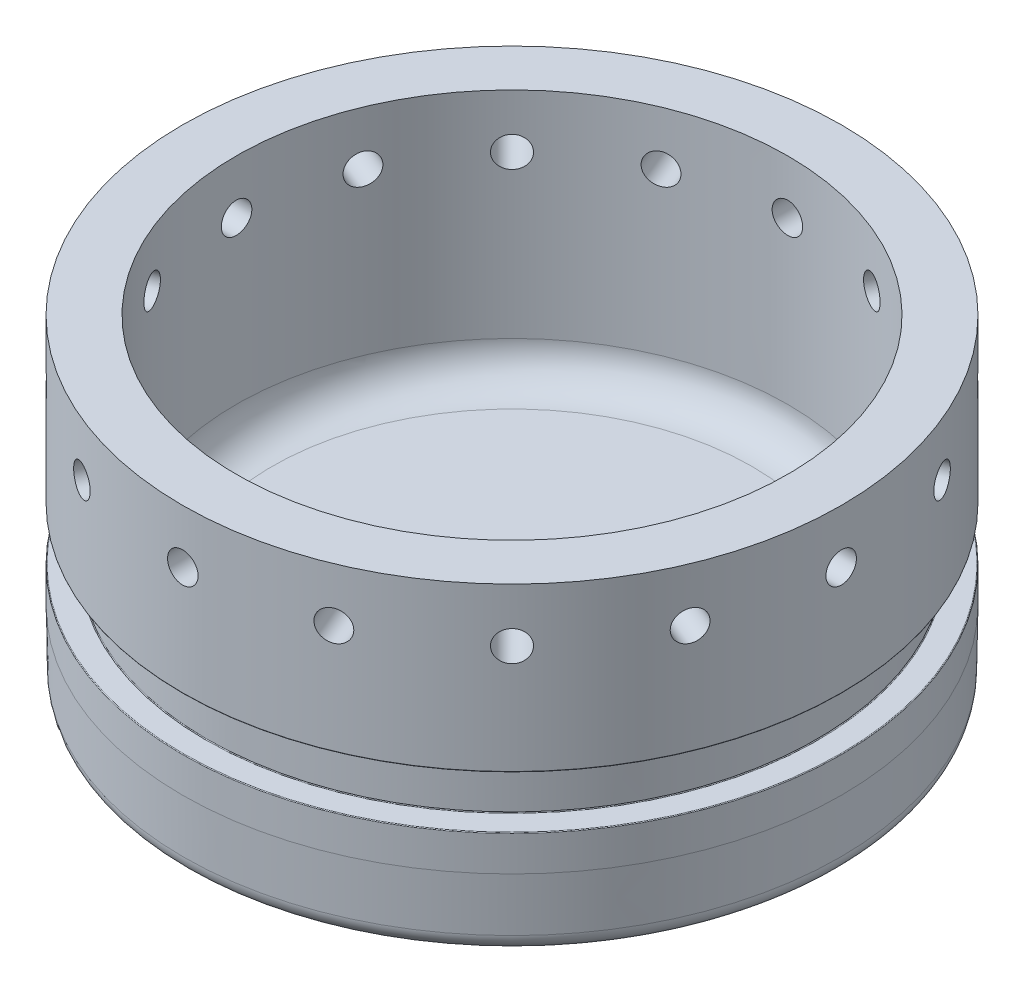
from build123d import *

# Parameters (mm, degrees)
POCKETFILLET_R                = 6.35
TAPERFILLET_R                 = 3.175
PIPE_TAP_DRILL_FOR_1_8_TAP1_D = 8.4328
FILLET3_R                     = 0.127
TAP_DRILL_FOR_1_4_28_TAP1_D   = 5.4102
HOLEPATTERN_COUNT             = 16


with BuildPart() as part:
    # Sketch1 → Revolve1 (revolve)
    with BuildSketch(Plane.XY):
        Polygon((0, 3.175), (0.221679325, -9.525), (58.4454, -9.525), (58.4454, 3.175), (9.525, 3.175), (9.525, 47.7012), (0, 47.7012), (0, 18.796), (4.318, 18.796), (4.318, 9.525), (0, 9.525), align=None)
    revolve(axis=Axis((58.4454, -9.525, 0), (0, 1, 0)))

    # PocketFillet
    pocketfillet_edges = [part.edges().sort_by_distance(p)[0] for p in [
        (107.3658, 3.175, 0),
    ]]
    fillet(pocketfillet_edges, radius=POCKETFILLET_R)

    # TaperFillet
    taperfillet_edges = [part.edges().sort_by_distance(p)[0] for p in [
        (116.669120675, -9.525, 0),
    ]]
    fillet(taperfillet_edges, radius=TAPERFILLET_R)

    # Pipe Tap Drill for 1/8 Tap1 (through all)
    with Locations(Plane(origin=(0, 3.175, 0), x_dir=(1, 0, 0), z_dir=(0, 1, 0))):
        with Locations((83.8454, 0)):
            Hole(PIPE_TAP_DRILL_FOR_1_8_TAP1_D / 2)

    # Fillet3
    fillet3_edges = [part.edges().sort_by_distance(p)[0] for p in [
        (116.8908, 9.525, 0),
        (112.5728, 9.525, 0),
        (112.5728, 18.796, 0),
        (116.8908, 18.796, 0),
    ]]
    fillet(fillet3_edges, radius=FILLET3_R)

    # Tap Drill for 1/4-28 Tap1 (through all)
    with Locations(Plane.XY.offset(58.4454)):
        with Locations((58.4454, 38.1762)):
            tap_drill_for_1_4_28_tap1 = Hole(TAP_DRILL_FOR_1_4_28_TAP1_D / 2)

    # HolePattern: Tap Drill for 1/4-28 Tap1 ×16 about axis
    holepattern_axis = Axis((58.4454, 47.7012, 0), (0, -1, 0))
    for i in range(1, HOLEPATTERN_COUNT):
        add(tap_drill_for_1_4_28_tap1.rotate(holepattern_axis, i * 360 / HOLEPATTERN_COUNT), mode=Mode.SUBTRACT)


solid = part.part
